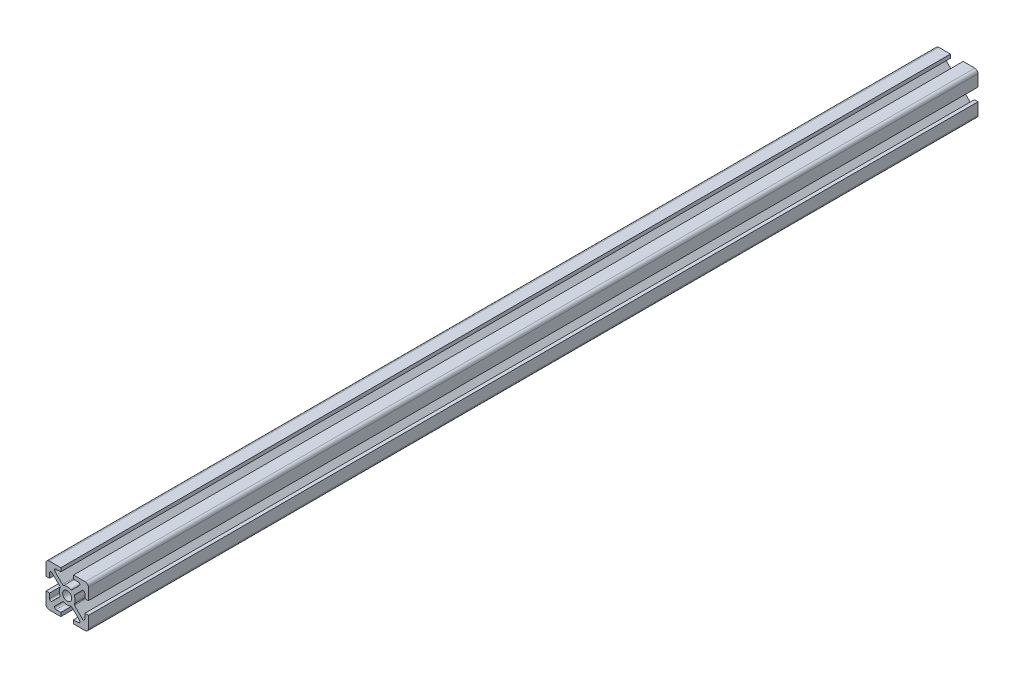
from build123d import *

# Parameters (mm, degrees)
ESQUISSE1_R        = 2.15
BOSS_EXTRU_1_DEPTH = 420


with BuildPart() as part:
    # Esquisse1 → Boss.-Extru.1 (new body)
    with BuildSketch(Plane.XY):
        with BuildLine():
            Line((-3, 10), (-8.5, 10))
            ThreePointArc((-8.5, 10), (-9.560660172, 9.560660172), (-10, 8.5))
            Line((-10, 8.5), (-10, 3))
            Line((-10, 3), (-8.300000103, 3))
            Line((-8.300000103, 3), (-8.300000103, 5.299391013))
            ThreePointArc((-8.300000103, 5.299391013), (-7.867878523, 5.946106661), (-7.105025403, 5.794365741))
            Line((-7.105025403, 5.794365741), (-3.486125569, 2.175465907))
            ThreePointArc((-3.486125569, 2.175465907), (-3.346986783, 1.907085393), (-3.38795202, 1.607569866))
            ThreePointArc((-3.38795202, 1.607569866), (-3.749999968, 1.37e-07), (-3.387952137, -1.607569618))
            ThreePointArc((-3.387952137, -1.607569618), (-3.346986918, -1.907085124), (-3.486125693, -2.175465617))
            Line((-3.486125693, -2.175465617), (-7.10502539, -5.794365497))
            ThreePointArc((-7.10502539, -5.794365497), (-7.867878514, -5.946106433), (-8.300000103, -5.299390782))
            Line((-8.300000103, -5.299390782), (-8.300000103, -3))
            Line((-8.300000103, -3), (-10, -3))
            Line((-10, -3), (-10, -8.5))
            ThreePointArc((-10, -8.5), (-9.560660172, -9.560660172), (-8.5, -10))
            Line((-8.5, -10), (-3, -10))
            Line((-3, -10), (-3, -8.29999992))
            Line((-3, -8.29999992), (-5.299390173, -8.29999992))
            ThreePointArc((-5.299390173, -8.29999992), (-5.94610582, -7.867878342), (-5.794364905, -7.105025224))
            Line((-5.794364905, -7.105025224), (-2.175465502, -3.486125765))
            ThreePointArc((-2.175465502, -3.486125765), (-1.907085014, -3.346986981), (-1.607569506, -3.38795219))
            ThreePointArc((-1.607569506, -3.38795219), (1.99e-07, -3.749999968), (1.607569866, -3.38795202))
            ThreePointArc((1.607569866, -3.38795202), (1.907085393, -3.346986783), (2.175465907, -3.486125569))
            Line((2.175465907, -3.486125569), (5.794365558, -7.10502522))
            ThreePointArc((5.794365558, -7.10502522), (5.946106478, -7.86787834), (5.29939083, -8.29999992))
            Line((5.29939083, -8.29999992), (3, -8.29999992))
            Line((3, -8.29999992), (3, -10))
            Line((3, -10), (8.499999896, -10))
            ThreePointArc((8.499999896, -10), (9.560660068, -9.560660172), (9.999999896, -8.5))
            Line((9.999999896, -8.5), (9.999999896, -3))
            Line((9.999999896, -3), (8.300000103, -3))
            Line((8.300000103, -3), (8.300000103, -5.299391569))
            ThreePointArc((8.300000103, -5.299391569), (7.867878509, -5.946107222), (7.105025381, -5.794366275))
            Line((7.105025381, -5.794366275), (3.486125475, -2.175466057))
            ThreePointArc((3.486125475, -2.175466057), (3.346986701, -1.907085538), (3.38795195, -1.607570012))
            ThreePointArc((3.38795195, -1.607570012), (3.658368452, -0.823917488), (3.749999968, 0))
            ThreePointArc((3.749999968, 0), (3.658368507, 0.823917244), (3.387952165, 1.607569559))
            ThreePointArc((3.387952165, 1.607569559), (3.346986951, 1.907085066), (3.486125731, 2.175465556))
            Line((3.486125731, 2.175465556), (7.105025399, 5.79436528))
            ThreePointArc((7.105025399, 5.79436528), (7.86787852, 5.946106205), (8.300000103, 5.299390557))
            Line((8.300000103, 5.299390557), (8.300000103, 3))
            Line((8.300000103, 3), (9.999999896, 3))
            Line((9.999999896, 3), (9.999999896, 8.5))
            ThreePointArc((9.999999896, 8.5), (9.560660068, 9.560660172), (8.499999896, 10))
            Line((8.499999896, 10), (3.499999896, 10))
            Line((3.499999896, 10), (3, 10))
            Line((3, 10), (3, 8.29999992))
            Line((3, 8.29999992), (5.299389948, 8.29999992))
            ThreePointArc((5.299389948, 8.29999992), (5.946105592, 7.867878348), (5.794364688, 7.105025232))
            Line((5.794364688, 7.105025232), (2.175465441, 3.486125803))
            ThreePointArc((2.175465441, 3.486125803), (1.907084956, 3.346987014), (1.607569447, 3.387952218))
            ThreePointArc((1.607569447, 3.387952218), (-1.51e-07, 3.749999968), (-1.60756972, 3.387952089))
            ThreePointArc((-1.60756972, 3.387952089), (-1.907085249, 3.346986865), (-2.175465757, 3.486125663))
            Line((-2.175465757, 3.486125663), (-5.794365024, 7.105025241))
            ThreePointArc((-5.794365024, 7.105025241), (-5.946105917, 7.867878353), (-5.299390275, 8.29999992))
            Line((-5.299390275, 8.29999992), (-3, 8.29999992))
            Line((-3, 8.29999992), (-3, 10))
        make_face()
        Circle(ESQUISSE1_R, mode=Mode.SUBTRACT)
    extrude(amount=BOSS_EXTRU_1_DEPTH)


solid = part.part
